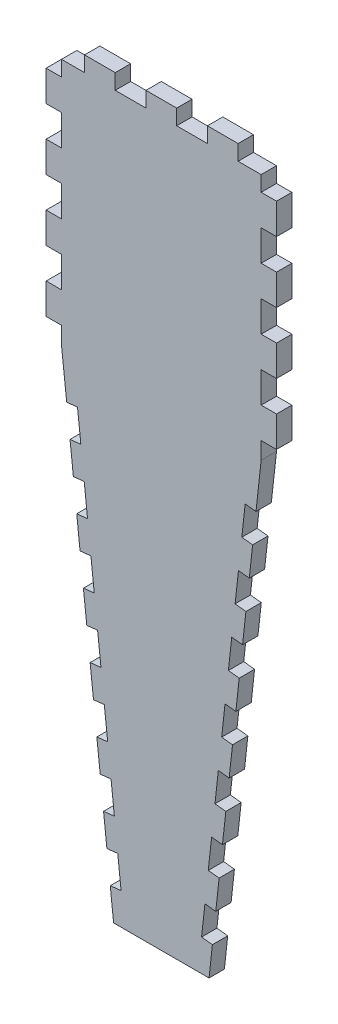
from build123d import *

# Parameters (mm, degrees)
SKETCH1_W           = 95.25
SKETCH1_H           = 304.8
BOSS_EXTRUDE1_DEPTH = 6.35
CUT_EXTRUDE1_DEPTH  = 7.35
SKETCH3_W           = 6.35
SKETCH3_H           = 12.7
CUT_EXTRUDE2_DEPTH  = 7.35
SKETCH4_W           = 9.525
SKETCH4_H           = 6.35
SKETCH4_W_2         = 12.7
CUT_EXTRUDE3_DEPTH  = 7.35
CUT_EXTRUDE4_DEPTH  = 7.35
LPATTERN2_COUNT     = 7
LPATTERN2_PITCH     = 25.4
CUT_EXTRUDE5_DEPTH  = 7.35
LPATTERN3_COUNT     = 7
LPATTERN3_PITCH     = 25.4
SKETCH9_W           = 6.35
SKETCH9_H           = 57.814016323
BOSS_EXTRUDE2_DEPTH = 6.35
LPATTERN4_COUNT     = 5
LPATTERN4_PITCH     = 25.4


with BuildPart() as part:
    # Sketch1 → Boss-Extrude1 (new body)
    with BuildSketch(Plane.XY):
        with Locations((47.625, 152.4)):
            Rectangle(SKETCH1_W, SKETCH1_H)
    extrude(amount=BOSS_EXTRUDE1_DEPTH)

    # Sketch2 → Cut-Extrude1 (cut, through all)
    with BuildSketch(Plane.XY.offset(6.35)):
        Polygon((0, 254), (27.898079092, 0), (0, 0), align=None)
        Polygon((67.351920908, 0), (95.25, 0), (95.25, 254), align=None)
    extrude(amount=-CUT_EXTRUDE1_DEPTH, mode=Mode.SUBTRACT)

    # Sketch3 → Cut-Extrude2 (cut, through all)
    with BuildSketch(Plane.XY.offset(6.35)):
        with Locations((3.175, 298.45)):
            Rectangle(SKETCH3_W, SKETCH3_H)
        with Locations((92.075, 298.45)):
            Rectangle(SKETCH3_W, SKETCH3_H)
    cut_extrude2 = extrude(amount=-CUT_EXTRUDE2_DEPTH, mode=Mode.SUBTRACT)

    # Sketch4 → Cut-Extrude3 (cut, through all)
    with BuildSketch(Plane.XY.offset(6.35)):
        with Locations((11.1125, 301.625)):
            Rectangle(SKETCH4_W, SKETCH4_H)
        with Locations((34.925, 301.625)):
            Rectangle(SKETCH4_W_2, SKETCH4_H)
        with Locations((60.325, 301.625)):
            Rectangle(SKETCH4_W_2, SKETCH4_H)
        with Locations((84.1375, 301.625)):
            Rectangle(SKETCH4_W, SKETCH4_H)
    extrude(amount=-CUT_EXTRUDE3_DEPTH, mode=Mode.SUBTRACT)

    # Sketch5 → Cut-Extrude4 (cut, through all)
    with BuildSketch(Plane.XY.offset(6.35)):
        Polygon((26.511513632, 12.624081599), (25.124948171, 25.248163198), (29.601595278, 25.739855541), (30.988160739, 13.115773942), align=None)
    cut_extrude4 = extrude(amount=-CUT_EXTRUDE4_DEPTH, mode=Mode.SUBTRACT)

    # LPattern2: Cut-Extrude4 ×7
    with Locations(*[Vector(-0.109178383, 0.994022173, 0) * (i * LPATTERN2_PITCH) for i in range(1, LPATTERN2_COUNT)]):
        add(cut_extrude4, mode=Mode.SUBTRACT)

    # Sketch6 → Cut-Extrude5 (cut, through all)
    with BuildSketch(Plane.XY.offset(6.35)):
        Polygon((68.738486368, 12.624081599), (70.125051829, 25.248163198), (65.648404722, 25.739855541), (64.261839261, 13.115773942), align=None)
    cut_extrude5 = extrude(amount=-CUT_EXTRUDE5_DEPTH, mode=Mode.SUBTRACT)

    # LPattern3: Cut-Extrude5 ×7
    with Locations(*[Vector(0.109178383, 0.994022173, 0) * (i * LPATTERN3_PITCH) for i in range(1, LPATTERN3_COUNT)]):
        add(cut_extrude5, mode=Mode.SUBTRACT)

    # Sketch9 → Boss-Extrude2 (add, through all)
    with BuildSketch(Plane.XY.offset(6.35)):
        with Locations((3.175, 225.092991839)):
            Rectangle(SKETCH9_W, SKETCH9_H)
        with Locations((92.075, 225.092991839)):
            Rectangle(SKETCH9_W, SKETCH9_H)
    extrude(amount=-BOSS_EXTRUDE2_DEPTH)

    # LPattern4: Cut-Extrude2 ×5
    with Locations(*[(0, -i * LPATTERN4_PITCH, 0) for i in range(1, LPATTERN4_COUNT)]):
        add(cut_extrude2, mode=Mode.SUBTRACT)


solid = part.part
